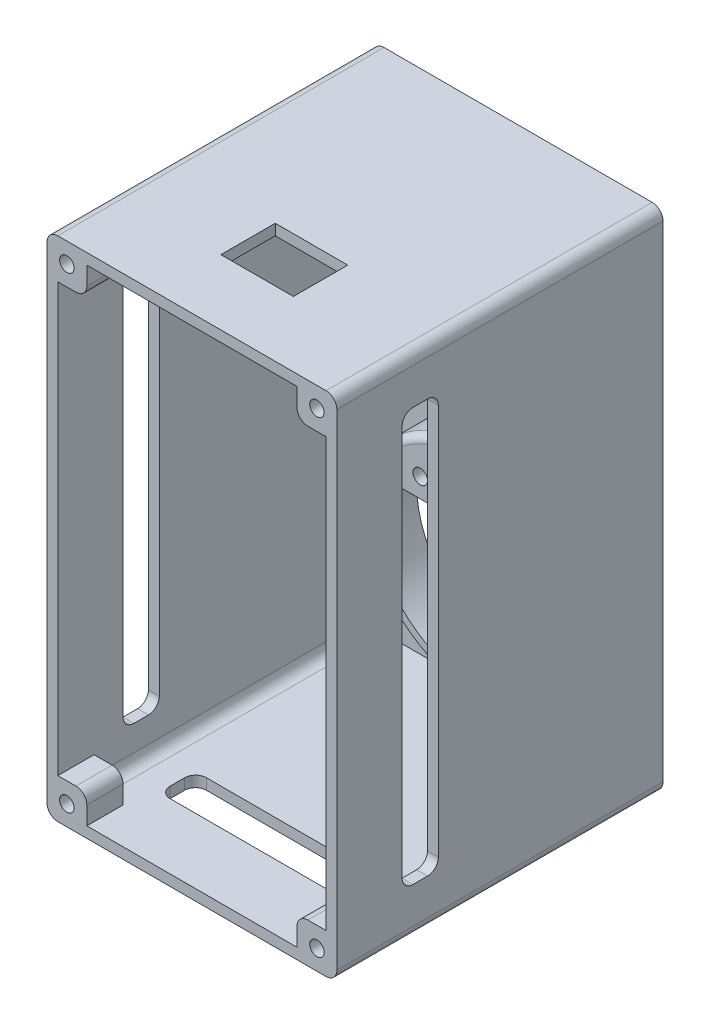
from build123d import *

# Parameters (mm, degrees)
SKETCH1_W               = 80
SKETCH1_H               = 80
BOSS_EXTRUDE1_DEPTH     = 80
SHELL1_T                = -3
CUT_EXTRUDE1_REACH      = 140.564
SKETCH2_R               = 27
SKETCH3_R               = 30
SKETCH3_R_2             = 27
BOSS_EXTRUDE2_DEPTH     = 9
BOSS_EXTRUDE3_DEPTH     = 3
SKETCH5_W               = 104.199084268
SKETCH5_H               = 10
CUT_EXTRUDE2_DEPTH      = 139.564064606
CUT_EXTRUDE2_DEPTH_BACK = 139.564064606
BOSS_EXTRUDE4_DEPTH     = 3
FILLET3_R               = 3
FILLET4_R               = 2
CUT_EXTRUDE5_REACH      = 129.138
SKETCH9_R               = 2
SKETCH13_W              = 80
SKETCH13_H              = 60
BOSS_EXTRUDE6_DEPTH     = 70
SKETCH14_W              = 74
SKETCH14_H              = 60
CUT_EXTRUDE8_DEPTH      = 67
SKETCH15_W              = 80
SKETCH15_H              = 140
SKETCH15_W_2            = 74
SKETCH15_H_2            = 134
BOSS_EXTRUDE7_DEPTH     = 20
SKETCH12_R              = 28
CUT_EXTRUDE7_DEPTH      = 12
FILLET5_R               = 3
SKETCH16_W              = 9.113547255
SKETCH16_H              = 9.484027798
SKETCH16_W_2            = 8
SKETCH16_H_2            = 8
BOSS_EXTRUDE8_DEPTH     = 10
SKETCH17_W              = 10
SKETCH17_H              = 114
CUT_EXTRUDE9_DEPTH      = 181
CUT_EXTRUDE10_START     = -10
SKETCH18_W              = 54
SKETCH18_H              = 10
CUT_EXTRUDE10_DEPTH     = 171
FILLET6_R               = 3
CUT_EXTRUDE11_REACH     = 186.662
SKETCH19_R              = 2
FILLET7_R               = 3
CUT_EXTRUDE12_REACH     = 182
SKETCH20_W              = 20
SKETCH20_H              = 15


with BuildPart() as part:
    # Sketch1 → Boss-Extrude1 (new body)
    with BuildSketch(Plane(origin=(0, 0, 0), x_dir=(1, 0, 0), z_dir=(0, 1, 0))):
        with Locations((40, 40)):
            Rectangle(SKETCH1_W, SKETCH1_H)
    extrude(amount=BOSS_EXTRUDE1_DEPTH)

    # Shell1
    shell1_openings = [part.faces().sort_by_distance(p)[0] for p in [
        (40, 40, 0),
    ]]
    offset(amount=SHELL1_T, openings=shell1_openings, kind=Kind.INTERSECTION)

    # Sketch2 → Cut-Extrude1 (cut, up to next)
    with BuildSketch(Plane(origin=(0, 0, -80), x_dir=(-1, 0, 0), z_dir=(0, 0, -1)), mode=Mode.PRIVATE) as cut_extrude1_sk1:
        with Locations((-40, 40)):
            Circle(SKETCH2_R)
    cut_extrude1_tool1 = extrude(cut_extrude1_sk1.sketch, amount=-CUT_EXTRUDE1_REACH, mode=Mode.PRIVATE) & part.part
    add(cut_extrude1_tool1.solids().sort_by_distance((40, 40, -80))[0], mode=Mode.SUBTRACT)

    # Sketch3 → Boss-Extrude2 (add)
    with BuildSketch(Plane.XY.offset(-77)):
        with Locations((40, 40)):
            Circle(SKETCH3_R)
        with Locations(Location((40, 40, 0), (0, 0, 180))):
            Circle(SKETCH3_R_2, mode=Mode.SUBTRACT)
    extrude(amount=BOSS_EXTRUDE2_DEPTH)

    # Sketch4 → Boss-Extrude3 (add)
    with BuildSketch(Plane.XY.offset(-68)):
        with BuildLine():
            Line((18, 60.396078054), (18, 19.603921946))
            ThreePointArc((18, 19.603921946), (10, 40), (18, 60.396078054))
        make_face()
        with BuildLine():
            Line((62, 60.396078054), (62, 19.603921946))
            ThreePointArc((62, 19.603921946), (70, 40), (62, 60.396078054))
        make_face()
    extrude(amount=BOSS_EXTRUDE3_DEPTH)

    # Sketch5 → Cut-Extrude2 (cut, two sides)
    with BuildSketch(Plane.XZ) as cut_extrude2_sk:
        with Locations((52.099542134, -5)):
            Rectangle(SKETCH5_W, SKETCH5_H)
    extrude(amount=CUT_EXTRUDE2_DEPTH, mode=Mode.SUBTRACT)
    extrude(cut_extrude2_sk.sketch, amount=-CUT_EXTRUDE2_DEPTH_BACK, mode=Mode.SUBTRACT)

    # Sketch8 → Boss-Extrude4 (add)
    with BuildSketch(Plane.XY.offset(-68)):
        with BuildLine():
            Line((18, 60.396078054), (18, 52.135192758))
            Line((18, 52.135192758), (62, 52.135192758))
            Line((62, 52.135192758), (62, 60.396078054))
            ThreePointArc((62, 60.396078054), (40, 70), (18, 60.396078054))
        make_face()
    extrude(amount=BOSS_EXTRUDE4_DEPTH)

    # Fillet3
    fillet3_edges = [part.edges().sort_by_distance(p)[0] for p in [
        (18, 52.135192758, -66.5),
        (62, 52.135192758, -66.5),
    ]]
    fillet(fillet3_edges, radius=FILLET3_R)

    # Fillet4
    fillet4_edges = [part.edges().sort_by_distance(p)[0] for p in [
        (40, 70, -65),
    ]]
    fillet(fillet4_edges, radius=FILLET4_R)

    # Sketch9 → Cut-Extrude5 (cut, up to next)
    with BuildSketch(Plane(origin=(0, 0, -68), x_dir=(-1, 0, 0), z_dir=(0, 0, -1)), mode=Mode.PRIVATE) as cut_extrude5_sk1:
        with Locations((-52, 57.5)):
            Circle(SKETCH9_R)
    cut_extrude5_tool1 = extrude(cut_extrude5_sk1.sketch, amount=-CUT_EXTRUDE5_REACH, mode=Mode.PRIVATE) & part.part
    # Sketch9 → Cut-Extrude5 (cut, up to next)
    with BuildSketch(Plane(origin=(0, 0, -68), x_dir=(-1, 0, 0), z_dir=(0, 0, -1)), mode=Mode.PRIVATE) as cut_extrude5_sk2:
        with Locations((-28, 57.5)):
            Circle(SKETCH9_R)
    cut_extrude5_tool2 = extrude(cut_extrude5_sk2.sketch, amount=-CUT_EXTRUDE5_REACH, mode=Mode.PRIVATE) & part.part
    add(cut_extrude5_tool1.solids().sort_by_distance((52, 57.5, -68))[0], mode=Mode.SUBTRACT)
    add(cut_extrude5_tool2.solids().sort_by_distance((28, 57.5, -68))[0], mode=Mode.SUBTRACT)

    # Sketch13 → Boss-Extrude6 (add)
    with BuildSketch(Plane(origin=(0, 0, -80), x_dir=(-1, 0, 0), z_dir=(0, 0, -1))):
        with Locations((-40, 110)):
            Rectangle(SKETCH13_W, SKETCH13_H)
    extrude(amount=-BOSS_EXTRUDE6_DEPTH)

    # Sketch14 → Cut-Extrude8 (cut)
    with BuildSketch(Plane.XY.offset(-10)):
        with Locations((40, 107)):
            Rectangle(SKETCH14_W, SKETCH14_H)
    extrude(amount=-CUT_EXTRUDE8_DEPTH, mode=Mode.SUBTRACT)

    # Sketch15 → Boss-Extrude7 (add)
    with BuildSketch(Plane.XY.offset(-10)):
        with Locations((40, 70)):
            Rectangle(SKETCH15_W, SKETCH15_H)
        with Locations((40, 70)):
            Rectangle(SKETCH15_W_2, SKETCH15_H_2, mode=Mode.SUBTRACT)
    extrude(amount=BOSS_EXTRUDE7_DEPTH)

    # Sketch12 → Cut-Extrude7 (cut)
    with BuildSketch(Plane(origin=(0, 0, -80), x_dir=(-1, 0, 0), z_dir=(0, 0, -1))):
        with Locations((-40, 40)):
            Circle(SKETCH12_R)
    extrude(amount=-CUT_EXTRUDE7_DEPTH, mode=Mode.SUBTRACT)

    # Fillet5
    fillet5_edges = [part.edges().sort_by_distance(p)[0] for p in [
        (80, 140, -45),
        (0, 140, -45),
        (3, 137, -43.5),
        (77, 137, -43.5),
        (3, 3, -43.5),
        (77, 3, -43.5),
        (0, 0, -45),
        (80, 0, -45),
    ]]
    fillet(fillet5_edges, radius=FILLET5_R)

    # Sketch16 → Boss-Extrude8 (add)
    with BuildSketch(Plane.XY.offset(10)):
        with Locations((6.443226372, 6.257986101)):
            Rectangle(SKETCH16_W, SKETCH16_H)
        with Locations((73, 7)):
            Rectangle(SKETCH16_W_2, SKETCH16_H_2)
        with Locations((73, 133)):
            Rectangle(SKETCH16_W_2, SKETCH16_H_2)
        with Locations((7, 133)):
            Rectangle(SKETCH16_W_2, SKETCH16_H_2)
    extrude(amount=-BOSS_EXTRUDE8_DEPTH)

    # Sketch17 → Cut-Extrude9 (cut, through all)
    with BuildSketch(Plane.ZY):
        with Locations((-13, 70)):
            Rectangle(SKETCH17_W, SKETCH17_H)
    extrude(amount=-CUT_EXTRUDE9_DEPTH, mode=Mode.SUBTRACT)

    # Sketch18 → Cut-Extrude10 (cut, through all)
    with BuildSketch(Plane(origin=(0, 140, 0), x_dir=(1, 0, 0), z_dir=(0, 1, 0)).offset(CUT_EXTRUDE10_START)):
        with Locations((40, 13)):
            Rectangle(SKETCH18_W, SKETCH18_H)
    extrude(amount=-CUT_EXTRUDE10_DEPTH, mode=Mode.SUBTRACT)

    # Fillet6
    fillet6_edges = [part.edges().sort_by_distance(p)[0] for p in [
        (1.5, 13, -18),
        (1.5, 127, -18),
        (1.5, 127, -8),
        (1.5, 13, -8),
        (78.5, 13, -18),
        (78.5, 127, -18),
        (78.5, 127, -8),
        (78.5, 13, -8),
        (13, 1.5, -8),
        (13, 1.5, -18),
        (67, 1.5, -18),
        (67, 1.5, -8),
    ]]
    fillet(fillet6_edges, radius=FILLET6_R)

    # Sketch19 → Cut-Extrude11 (cut, up to next)
    with BuildSketch(Plane.XY.offset(10), mode=Mode.PRIVATE) as cut_extrude11_sk1:
        with Locations((5.5, 134.5)):
            Circle(SKETCH19_R)
    cut_extrude11_tool1 = extrude(cut_extrude11_sk1.sketch, amount=-CUT_EXTRUDE11_REACH, mode=Mode.PRIVATE) & part.part
    # Sketch19 → Cut-Extrude11 (cut, up to next)
    with BuildSketch(Plane.XY.offset(10), mode=Mode.PRIVATE) as cut_extrude11_sk2:
        with Locations((74.5, 134.5)):
            Circle(SKETCH19_R)
    cut_extrude11_tool2 = extrude(cut_extrude11_sk2.sketch, amount=-CUT_EXTRUDE11_REACH, mode=Mode.PRIVATE) & part.part
    # Sketch19 → Cut-Extrude11 (cut, up to next)
    with BuildSketch(Plane.XY.offset(10), mode=Mode.PRIVATE) as cut_extrude11_sk3:
        with Locations((74.5, 5.5)):
            Circle(SKETCH19_R)
    cut_extrude11_tool3 = extrude(cut_extrude11_sk3.sketch, amount=-CUT_EXTRUDE11_REACH, mode=Mode.PRIVATE) & part.part
    # Sketch19 → Cut-Extrude11 (cut, up to next)
    with BuildSketch(Plane.XY.offset(10), mode=Mode.PRIVATE) as cut_extrude11_sk4:
        with Locations((5.5, 5.5)):
            Circle(SKETCH19_R)
    cut_extrude11_tool4 = extrude(cut_extrude11_sk4.sketch, amount=-CUT_EXTRUDE11_REACH, mode=Mode.PRIVATE) & part.part
    add(cut_extrude11_tool1.solids().sort_by_distance((5.5, 134.5, 10))[0], mode=Mode.SUBTRACT)
    add(cut_extrude11_tool2.solids().sort_by_distance((74.5, 134.5, 10))[0], mode=Mode.SUBTRACT)
    add(cut_extrude11_tool3.solids().sort_by_distance((74.5, 5.5, 10))[0], mode=Mode.SUBTRACT)
    add(cut_extrude11_tool4.solids().sort_by_distance((5.5, 5.5, 10))[0], mode=Mode.SUBTRACT)

    # Fillet7
    fillet7_edges = [part.edges().sort_by_distance(p)[0] for p in [
        (11, 11, 5),
        (69, 11, 5),
        (69, 129, 5),
        (11, 129, 5),
    ]]
    fillet(fillet7_edges, radius=FILLET7_R)

    # Sketch20 → Cut-Extrude12 (cut, up to next)
    with BuildSketch(Plane(origin=(0, 140, 0), x_dir=(1, 0, 0), z_dir=(0, 1, 0)), mode=Mode.PRIVATE) as cut_extrude12_sk1:
        with Locations((40, 15.5)):
            Rectangle(SKETCH20_W, SKETCH20_H)
    cut_extrude12_tool1 = extrude(cut_extrude12_sk1.sketch, amount=-CUT_EXTRUDE12_REACH, mode=Mode.PRIVATE) & part.part
    add(cut_extrude12_tool1.solids().sort_by_distance((40, 140, -15.5))[0], mode=Mode.SUBTRACT)


solid = part.part
